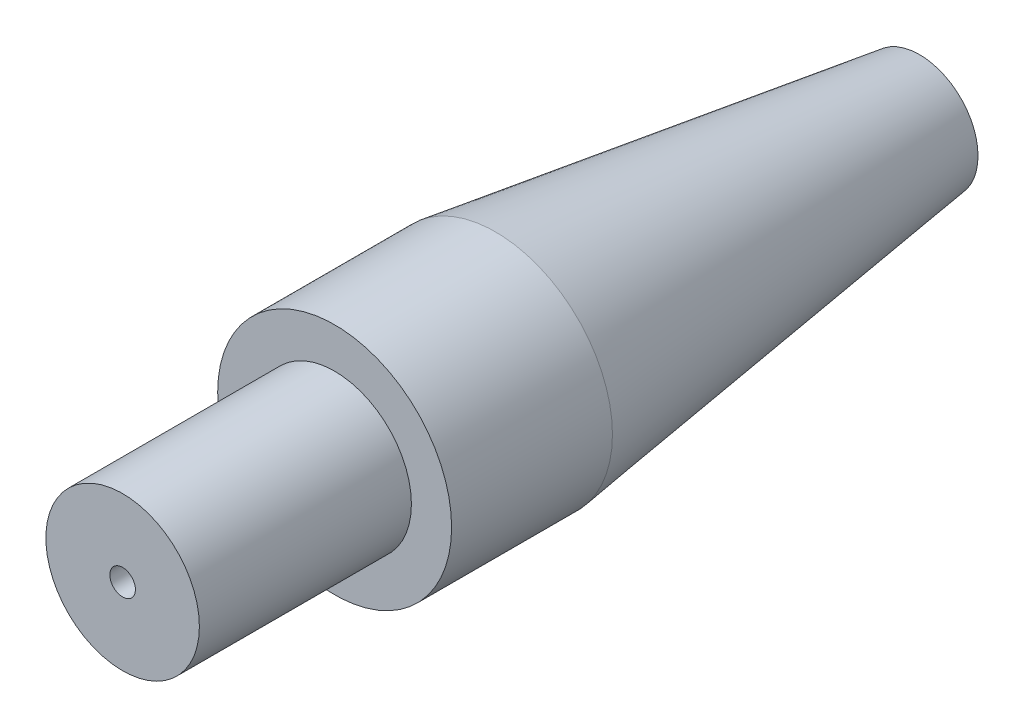
from build123d import *


with BuildPart() as part:
    # Sketch2 → Revolve1 (revolve)
    with BuildSketch(Plane(origin=(0, 0, 0), x_dir=(1, 0, 0), z_dir=(0, 1, 0))):
        Polygon((0.4445, 20.32), (0.4445, -7.366), (2.667, -7.366), (2.667, 0), (4.064, 0), (4.064, 5.588), (2.032, 20.32), align=None)
    revolve(axis=Axis((0, 0, 0), (0, 0, -1)))


solid = part.part
